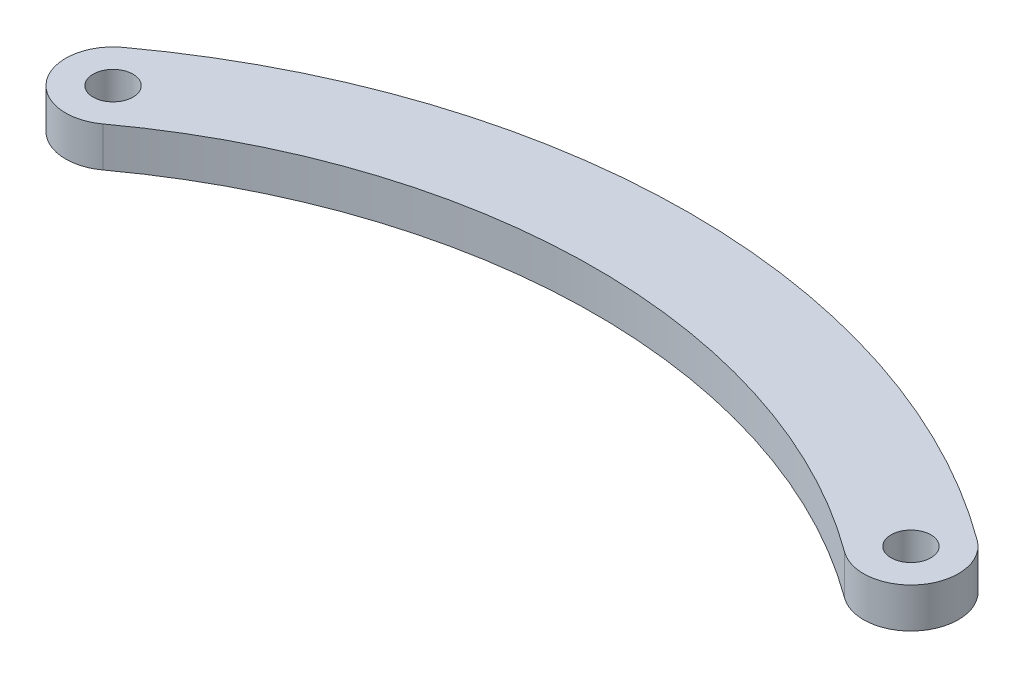
from build123d import *

# Parameters (mm, degrees)
BOSS_EXTRUDE1_DEPTH = 3.175
SKETCH3_R           = 1.5875
CUT_EXTRUDE1_DEPTH  = 3.175


with BuildPart() as part:
    # Sketch2 → Boss-Extrude1 (new body)
    with BuildSketch(Plane(origin=(0, 0, 0), x_dir=(1, 0, 0), z_dir=(0, 1, 0))):
        with BuildLine():
            ThreePointArc((36.339836195, 0.843949489), (2.357673267, 11.966979488), (-31.62448966, 0.843949489))
            ThreePointArc((-31.62448966, 0.843949489), (-32.436771272, -4.432657977), (-27.160163805, -5.244939588))
            ThreePointArc((-27.160163805, -5.244939588), (2.357673267, 4.416828792), (31.87551034, -5.244939588))
            ThreePointArc((31.87551034, -5.244939588), (37.152117806, -4.432657977), (36.339836195, 0.843949489))
        make_face()
    extrude(amount=BOSS_EXTRUDE1_DEPTH)

    # Sketch3 → Cut-Extrude1 (cut)
    with BuildSketch(Plane(origin=(0, 3.175, 0), x_dir=(1, 0, 0), z_dir=(0, 1, 0))):
        with Locations((-29.392326733, -2.20049505)):
            Circle(SKETCH3_R)
        with Locations((34.107673267, -2.20049505)):
            Circle(SKETCH3_R)
    extrude(amount=-CUT_EXTRUDE1_DEPTH, mode=Mode.SUBTRACT)


solid = part.part
